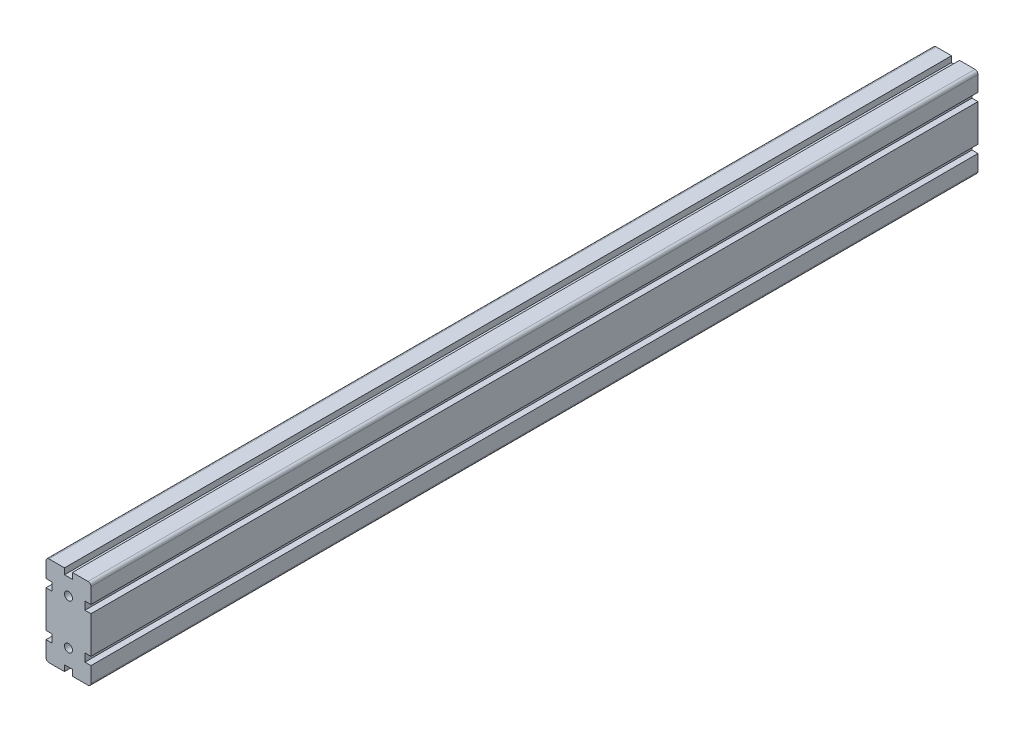
from build123d import *

# Parameters (mm, degrees)
ESQUISSE1_R        = 4
BOSS_EXTRU_1_DEPTH = 888


with BuildPart() as part:
    # Esquisse1 → Boss.-Extru.1 (new body)
    with BuildSketch(Plane(origin=(0, 0, -1000), x_dir=(-1, 0, 0), z_dir=(0, 0, -1))):
        with BuildLine():
            Line((16.5, 26.5), (22.5, 26.5))
            Line((22.5, 26.5), (22.5, 42))
            ThreePointArc((22.5, 42), (21.621320344, 44.121320344), (19.5, 45))
            Line((19.5, 45), (4, 45))
            Line((4, 45), (4, 39))
            Line((4, 39), (-4, 39))
            Line((-4, 39), (-4, 45))
            Line((-4, 45), (-19.5, 45))
            ThreePointArc((-19.5, 45), (-21.621320344, 44.121320344), (-22.5, 42))
            Line((-22.5, 42), (-22.5, 26.5))
            Line((-22.5, 26.5), (-16.5, 26.5))
            Line((-16.5, 26.5), (-16.5, 18.5))
            Line((-16.5, 18.5), (-22.5, 18.5))
            Line((-22.5, 18.5), (-22.5, -18.5))
            Line((-22.5, -18.5), (-16.5, -18.5))
            Line((-16.5, -18.5), (-16.5, -26.5))
            Line((-16.5, -26.5), (-22.5, -26.5))
            Line((-22.5, -26.5), (-22.5, -42))
            ThreePointArc((-22.5, -42), (-21.621320344, -44.121320344), (-19.5, -45))
            Line((-19.5, -45), (-4, -45))
            Line((-4, -45), (-4, -39))
            Line((-4, -39), (4, -39))
            Line((4, -39), (4, -45))
            Line((4, -45), (19.5, -45))
            ThreePointArc((19.5, -45), (21.621320344, -44.121320344), (22.5, -42))
            Line((22.5, -42), (22.5, -26.5))
            Line((22.5, -26.5), (16.5, -26.5))
            Line((16.5, -26.5), (16.5, -18.5))
            Line((16.5, -18.5), (22.5, -18.5))
            Line((22.5, -18.5), (22.5, 18.5))
            Line((22.5, 18.5), (16.5, 18.5))
            Line((16.5, 18.5), (16.5, 26.5))
        make_face()
        with Locations((0, 22.5)):
            Circle(ESQUISSE1_R, mode=Mode.SUBTRACT)
        with Locations((0, -22.5)):
            Circle(ESQUISSE1_R, mode=Mode.SUBTRACT)
    extrude(amount=-BOSS_EXTRU_1_DEPTH)


solid = part.part
